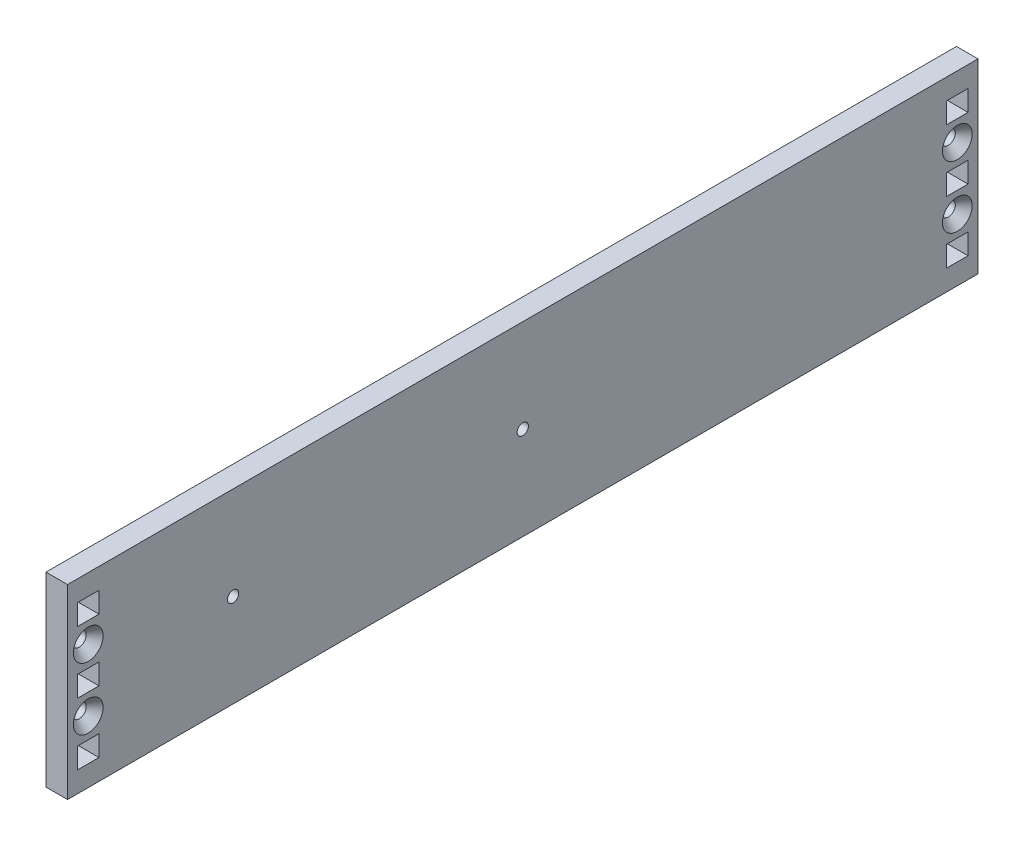
from build123d import *

# Parameters (mm, degrees)
SKETCH1_W                                         = 279.4
SKETCH1_H                                         = 57.15
SKETCH1_R                                         = 2.15265
SKETCH1_W_2                                       = 6.604
SKETCH1_H_2                                       = 6.35
BOSS_EXTRUDE1_DEPTH                               = 6.604
CSK_FOR_8_FLAT_HEAD_SOCKET_CAP_SCREW1_D           = 4.3053
CSK_FOR_8_FLAT_HEAD_SOCKET_CAP_SCREW1_CSINK_D     = 9.1186
CSK_FOR_8_FLAT_HEAD_SOCKET_CAP_SCREW1_CSINK_ANGLE = 82
F_8_32_TAPPED_HOLE1_D                             = 3.4544
F_8_32_TAPPED_HOLE1_DEPTH                         = 10.7188
F_8_32_TAPPED_HOLE1_TIP                           = 1.037806461


with BuildPart() as part:
    # Sketch1 → Boss-Extrude1 (new body)
    with BuildSketch(Plane(origin=(0, 0, 0), x_dir=(0, 0, -1), z_dir=(1, 0, 0))):
        Rectangle(SKETCH1_W, SKETCH1_H)
        with Locations((-133.35, 9.525)):
            Circle(SKETCH1_R, mode=Mode.SUBTRACT)
        with Locations((-133.35, -9.525)):
            Circle(SKETCH1_R, mode=Mode.SUBTRACT)
        with Locations((133.35, 9.525)):
            Circle(SKETCH1_R, mode=Mode.SUBTRACT)
        with Locations((133.35, -9.525)):
            Circle(SKETCH1_R, mode=Mode.SUBTRACT)
        with Locations((-133.35, 0)):
            Rectangle(SKETCH1_W_2, SKETCH1_H_2, mode=Mode.SUBTRACT)
        with Locations((-133.35, 19.05)):
            Rectangle(SKETCH1_W_2, SKETCH1_H_2, mode=Mode.SUBTRACT)
        with Locations((-133.35, -19.05)):
            Rectangle(SKETCH1_W_2, SKETCH1_H_2, mode=Mode.SUBTRACT)
        with Locations((133.35, 0)):
            Rectangle(SKETCH1_W_2, SKETCH1_H_2, mode=Mode.SUBTRACT)
        with Locations((133.35, 19.05)):
            Rectangle(SKETCH1_W_2, SKETCH1_H_2, mode=Mode.SUBTRACT)
        with Locations((133.35, -19.05)):
            Rectangle(SKETCH1_W_2, SKETCH1_H_2, mode=Mode.SUBTRACT)
    extrude(amount=BOSS_EXTRUDE1_DEPTH)

    # CSK for #8 Flat Head Socket Cap Screw1 (through all)
    with Locations(Plane(origin=(6.604, 0, 0), x_dir=(0, 0, -1), z_dir=(1, 0, 0))):
        with Locations((-133.35, 9.525), (-133.35, -9.525), (133.35, 9.525), (133.35, -9.525)):
            CounterSinkHole(CSK_FOR_8_FLAT_HEAD_SOCKET_CAP_SCREW1_D / 2, CSK_FOR_8_FLAT_HEAD_SOCKET_CAP_SCREW1_CSINK_D / 2, counter_sink_angle=CSK_FOR_8_FLAT_HEAD_SOCKET_CAP_SCREW1_CSINK_ANGLE)

    # #8-32 Tapped Hole1
    with Locations(Plane(origin=(6.604, 0, 0), x_dir=(0, 0, -1), z_dir=(1, 0, 0))):
        with Locations((-88.9, 0), (0, 0)):
            Hole(F_8_32_TAPPED_HOLE1_D / 2, depth=F_8_32_TAPPED_HOLE1_DEPTH)
            with Locations((0, 0, -(F_8_32_TAPPED_HOLE1_DEPTH + F_8_32_TAPPED_HOLE1_TIP / 2))):  # 118° drill point
                Cone(0, F_8_32_TAPPED_HOLE1_D / 2, F_8_32_TAPPED_HOLE1_TIP, mode=Mode.SUBTRACT)


solid = part.part
